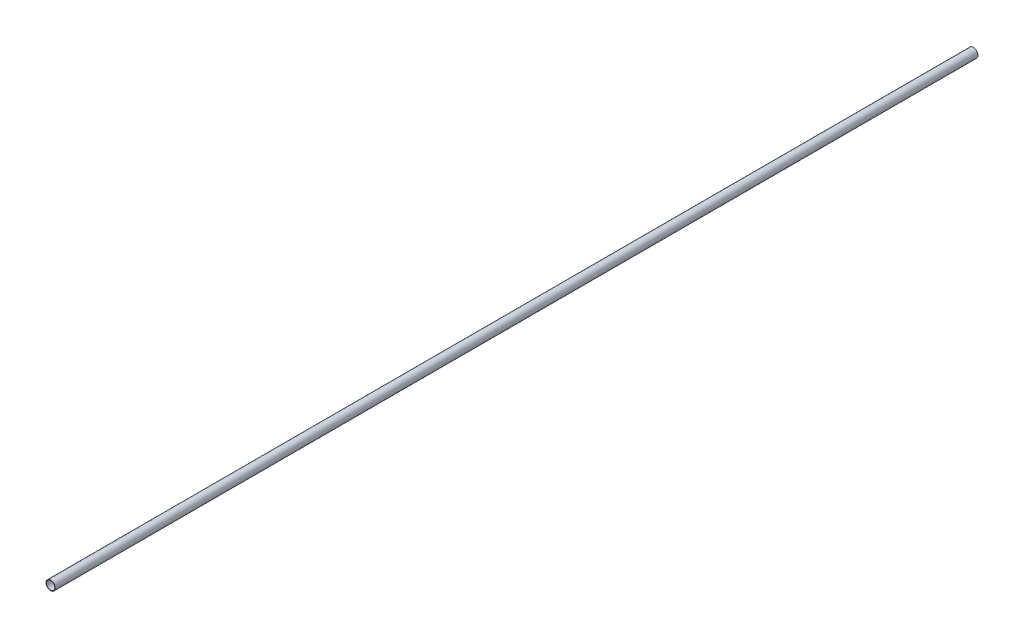
from build123d import *

# Parameters (mm, degrees)
SKETCH_1_R      = 5
SKETCH_1_R_2    = 4.5
EXTRUDE_1_DEPTH = 500


with BuildPart() as part:
    # Эскиз1 → Бобышка-Вытянуть1 (new body, symmetric)
    with BuildSketch(Plane.XY):
        Circle(SKETCH_1_R)
        Circle(SKETCH_1_R_2, mode=Mode.SUBTRACT)
    extrude(amount=EXTRUDE_1_DEPTH, both=True)


solid = part.part
